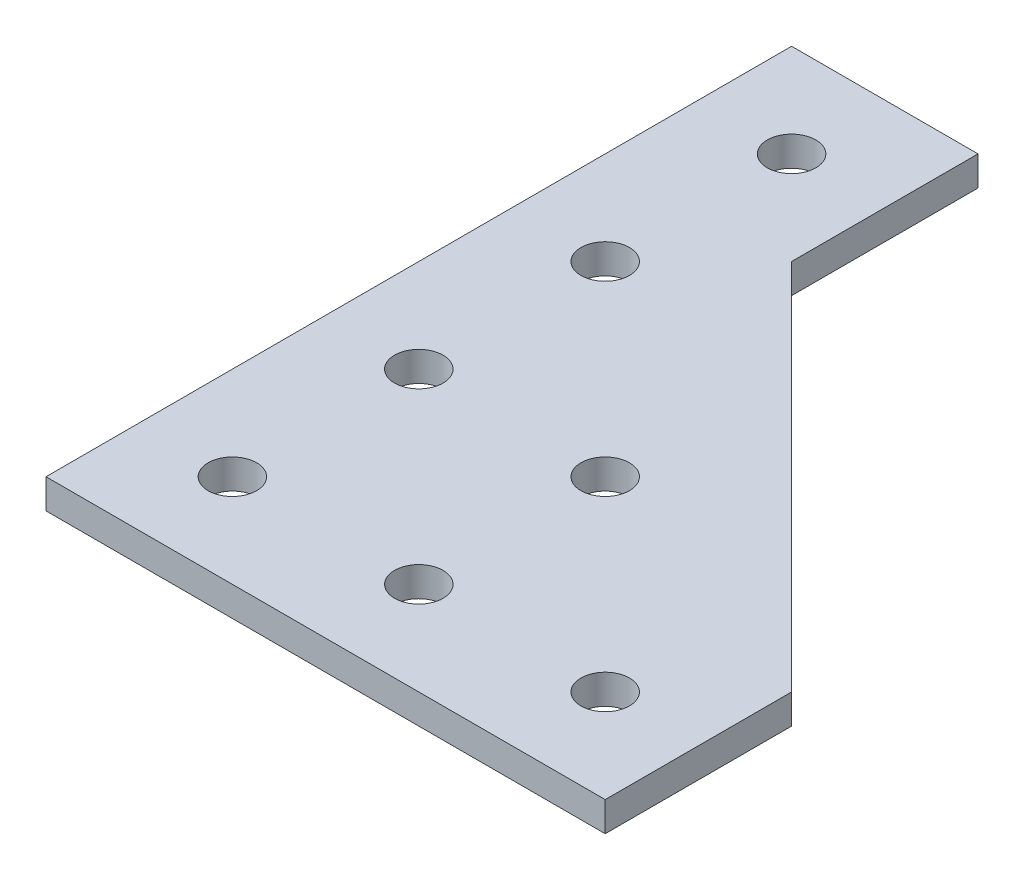
from build123d import *

# Parameters (mm, degrees)
SKETCH1_R           = 2.6
BOSS_EXTRUDE1_DEPTH = 3.175


with BuildPart() as part:
    # Sketch1 → Boss-Extrude1 (new body)
    with BuildSketch(Plane(origin=(0, 0, 0), x_dir=(1, 0, 0), z_dir=(0, 1, 0))):
        Polygon((60, 20), (20, 60), (20, 80), (0, 80), (0, 0), (60, 0), align=None)
        with Locations((30, 10)):
            Circle(SKETCH1_R, mode=Mode.SUBTRACT)
        with Locations((50, 10)):
            Circle(SKETCH1_R, mode=Mode.SUBTRACT)
        with Locations((30, 30)):
            Circle(SKETCH1_R, mode=Mode.SUBTRACT)
        with Locations((10, 10)):
            Circle(SKETCH1_R, mode=Mode.SUBTRACT)
        with Locations((10, 30)):
            Circle(SKETCH1_R, mode=Mode.SUBTRACT)
        with Locations((10, 50)):
            Circle(SKETCH1_R, mode=Mode.SUBTRACT)
        with Locations((10, 70)):
            Circle(SKETCH1_R, mode=Mode.SUBTRACT)
    extrude(amount=BOSS_EXTRUDE1_DEPTH)


solid = part.part
